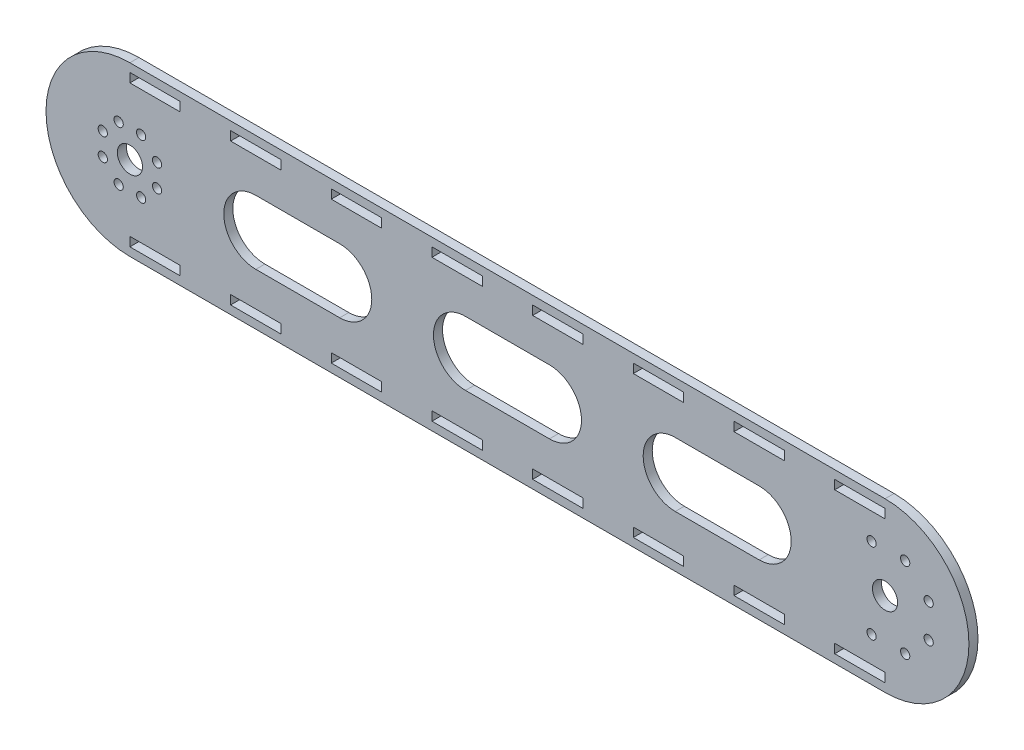
from build123d import *

# Parameters (mm, degrees)
SKETCH3_R           = 7.5
SKETCH3_R_2         = 2.75
BOSS_EXTRUDE1_DEPTH = 5.4
SKETCH4_W           = 30
SKETCH4_H           = 5.4
CUT_EXTRUDE1_DEPTH  = 6.4


with BuildPart() as part:
    # Sketch3 → Boss-Extrude1 (new body)
    with BuildSketch(Plane.XY):
        with BuildLine():
            Line((-20.962749028, 50), (429.037250972, 50))
            ThreePointArc((429.037250972, 50), (479.037250972, 0), (429.037250972, -50))
            Line((429.037250972, -50), (-20.962749028, -50))
            ThreePointArc((-20.962749028, -50), (-70.962749028, 0), (-20.962749028, 50))
        make_face()
        with Locations((-20.962749028, 0)):
            Circle(SKETCH3_R, mode=Mode.SUBTRACT)
        with Locations((429.037250972, 0)):
            Circle(SKETCH3_R, mode=Mode.SUBTRACT)
        with Locations((-4.794857209, 6.696960066)):
            Circle(SKETCH3_R_2, mode=Mode.SUBTRACT)
        with Locations((-4.794857209, -6.696960066)):
            Circle(SKETCH3_R_2, mode=Mode.SUBTRACT)
        with Locations((-14.265788962, -16.167891819)):
            Circle(SKETCH3_R_2, mode=Mode.SUBTRACT)
        with Locations((-27.659709094, -16.167891819)):
            Circle(SKETCH3_R_2, mode=Mode.SUBTRACT)
        with Locations((-37.130640847, -6.696960066)):
            Circle(SKETCH3_R_2, mode=Mode.SUBTRACT)
        with Locations((-37.130640847, 6.696960066)):
            Circle(SKETCH3_R_2, mode=Mode.SUBTRACT)
        with Locations((-27.659709094, 16.167891819)):
            Circle(SKETCH3_R_2, mode=Mode.SUBTRACT)
        with Locations((-14.265788962, 16.167891819)):
            Circle(SKETCH3_R_2, mode=Mode.SUBTRACT)
        with Locations((455.037250972, 10)):
            Circle(SKETCH3_R_2, mode=Mode.SUBTRACT)
        with Locations((441.037250972, 24)):
            Circle(SKETCH3_R_2, mode=Mode.SUBTRACT)
        with Locations((421.037250972, 24)):
            Circle(SKETCH3_R_2, mode=Mode.SUBTRACT)
        with Locations((455.037250972, -10)):
            Circle(SKETCH3_R_2, mode=Mode.SUBTRACT)
        with Locations((441.037250972, -24)):
            Circle(SKETCH3_R_2, mode=Mode.SUBTRACT)
        with Locations((421.037250972, -24)):
            Circle(SKETCH3_R_2, mode=Mode.SUBTRACT)
        with BuildLine():
            Line((179.037250972, 19.094555463), (229.037250972, 19.094555463))
            ThreePointArc((229.037250972, 19.094555463), (248.131806435, 0), (229.037250972, -19.094555463))
            Line((229.037250972, -19.094555463), (179.037250972, -19.094555463))
            ThreePointArc((179.037250972, -19.094555463), (159.942695509, 0), (179.037250972, 19.094555463))
        make_face(mode=Mode.SUBTRACT)
        with BuildLine():
            Line((304.005250972, 19.094555463), (354.005250972, 19.094555463))
            ThreePointArc((354.005250972, 19.094555463), (373.099806435, 0), (354.005250972, -19.094555463))
            Line((354.005250972, -19.094555463), (304.005250972, -19.094555463))
            ThreePointArc((304.005250972, -19.094555463), (284.910695509, 0), (304.005250972, 19.094555463))
        make_face(mode=Mode.SUBTRACT)
        with BuildLine():
            Line((54.069250972, 19.094555463), (104.069250972, 19.094555463))
            ThreePointArc((104.069250972, 19.094555463), (123.163806435, 0), (104.069250972, -19.094555463))
            Line((104.069250972, -19.094555463), (54.069250972, -19.094555463))
            ThreePointArc((54.069250972, -19.094555463), (34.974695509, 0), (54.069250972, 19.094555463))
        make_face(mode=Mode.SUBTRACT)
    extrude(amount=BOSS_EXTRUDE1_DEPTH)

    # Sketch4 → Cut-Extrude1 (cut, through all)
    with BuildSketch(Plane.XY.offset(5.4)):
        with Locations((-5.962749028, 42.3)):
            Rectangle(SKETCH4_W, SKETCH4_H)
        with Locations((54.037250972, 42.3)):
            Rectangle(SKETCH4_W, SKETCH4_H)
        with Locations((114.037250972, 42.3)):
            Rectangle(SKETCH4_W, SKETCH4_H)
        with Locations((174.037250972, 42.3)):
            Rectangle(SKETCH4_W, SKETCH4_H)
        with Locations((234.037250972, 42.3)):
            Rectangle(SKETCH4_W, SKETCH4_H)
        with Locations((294.037250972, 42.3)):
            Rectangle(SKETCH4_W, SKETCH4_H)
        with Locations((354.037250972, 42.3)):
            Rectangle(SKETCH4_W, SKETCH4_H)
        with Locations((414.037250972, 42.3)):
            Rectangle(SKETCH4_W, SKETCH4_H)
        with Locations((414.037250972, -42.3)):
            Rectangle(SKETCH4_W, SKETCH4_H)
        with Locations((354.037250972, -42.3)):
            Rectangle(SKETCH4_W, SKETCH4_H)
        with Locations((294.037250972, -42.3)):
            Rectangle(SKETCH4_W, SKETCH4_H)
        with Locations((234.037250972, -42.3)):
            Rectangle(SKETCH4_W, SKETCH4_H)
        with Locations((174.037250972, -42.3)):
            Rectangle(SKETCH4_W, SKETCH4_H)
        with Locations((114.037250972, -42.3)):
            Rectangle(SKETCH4_W, SKETCH4_H)
        with Locations((54.037250972, -42.3)):
            Rectangle(SKETCH4_W, SKETCH4_H)
        with Locations((-5.962749028, -42.3)):
            Rectangle(SKETCH4_W, SKETCH4_H)
    extrude(amount=-CUT_EXTRUDE1_DEPTH, mode=Mode.SUBTRACT)


solid = part.part
